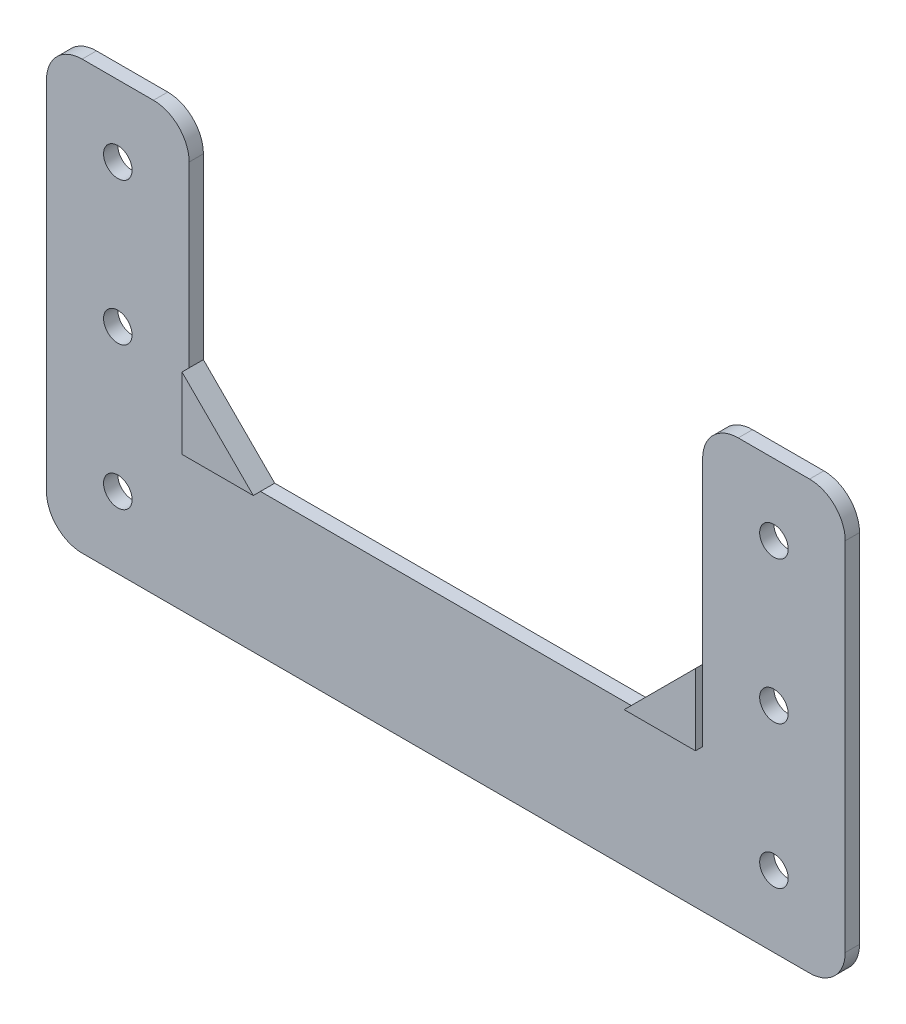
from build123d import *

# Parameters (mm, degrees)
EXTRUDE_1_DEPTH     = 3
SKETCH_3_R          = 2
CUT_EXTRUDE_2_DEPTH = 10
FILLET_2_R          = 5
CHAMFER_1_SIZE      = 10
CUT_EXTRUDE_3_DEPTH = 1


with BuildPart() as part:
    # ｽｹｯﾁ1 → ﾎﾞｽ - 押し出し1 (new body)
    with BuildSketch(Plane.XY):
        Polygon((-56, 30), (-56, -30), (56, -30), (56, 30), (36, 30), (36, -10), (-36, -10), (-36, 30), align=None)
    extrude(amount=EXTRUDE_1_DEPTH)

    # ｽｹｯﾁ3 → ｶｯﾄ - 押し出し2 (cut)
    with BuildSketch(Plane.XY.offset(3)):
        with Locations((-46, -20)):
            Circle(SKETCH_3_R)
        with Locations((46, -20)):
            Circle(SKETCH_3_R)
        with Locations((46, 0)):
            Circle(SKETCH_3_R)
        with Locations((-46, 0)):
            Circle(SKETCH_3_R)
        with Locations((-46, 20)):
            Circle(SKETCH_3_R)
        with Locations((46, 20)):
            Circle(SKETCH_3_R)
    extrude(amount=-CUT_EXTRUDE_2_DEPTH, mode=Mode.SUBTRACT)

    # ﾌｨﾚｯﾄ2
    fillet_2_edges = [part.edges().sort_by_distance(p)[0] for p in [
        (36, 30, 1.5),
        (56, 30, 1.5),
        (56, -30, 1.5),
        (-56, -30, 1.5),
        (-56, 30, 1.5),
        (-36, 30, 1.5),
    ]]
    fillet(fillet_2_edges, radius=FILLET_2_R)

    # 面取り1
    chamfer_1_edges = [part.edges().sort_by_distance(p)[0] for p in [
        (36, -10, 1.5),
        (-36, -10, 1.5),
    ]]
    chamfer(chamfer_1_edges, length=CHAMFER_1_SIZE)

    # ｽｹｯﾁ4 → ｶｯﾄ - 押し出し3 (cut)
    with BuildSketch(Plane.XY.offset(3)):
        with BuildLine():
            Line((-36, 0), (-36, -10))
            Line((-36, -10), (-26, -10))
            Line((-26, -10), (26, -10))
            Line((26, -10), (36, -10))
            Line((36, -10), (36, 0))
            Line((36, 0), (36, 25))
            ThreePointArc((36, 25), (37.464466094, 28.535533906), (41, 30))
            Line((41, 30), (51, 30))
            ThreePointArc((51, 30), (54.535533906, 28.535533906), (56, 25))
            Line((56, 25), (56, -25))
            ThreePointArc((56, -25), (54.535533906, -28.535533906), (51, -30))
            Line((51, -30), (-51, -30))
            ThreePointArc((-51, -30), (-54.535533906, -28.535533906), (-56, -25))
            Line((-56, -25), (-56, 25))
            ThreePointArc((-56, 25), (-54.535533906, 28.535533906), (-51, 30))
            Line((-51, 30), (-41, 30))
            ThreePointArc((-41, 30), (-37.464466094, 28.535533906), (-36, 25))
            Line((-36, 25), (-36, 0))
        make_face()
    extrude(amount=-CUT_EXTRUDE_3_DEPTH, mode=Mode.SUBTRACT)


solid = part.part
